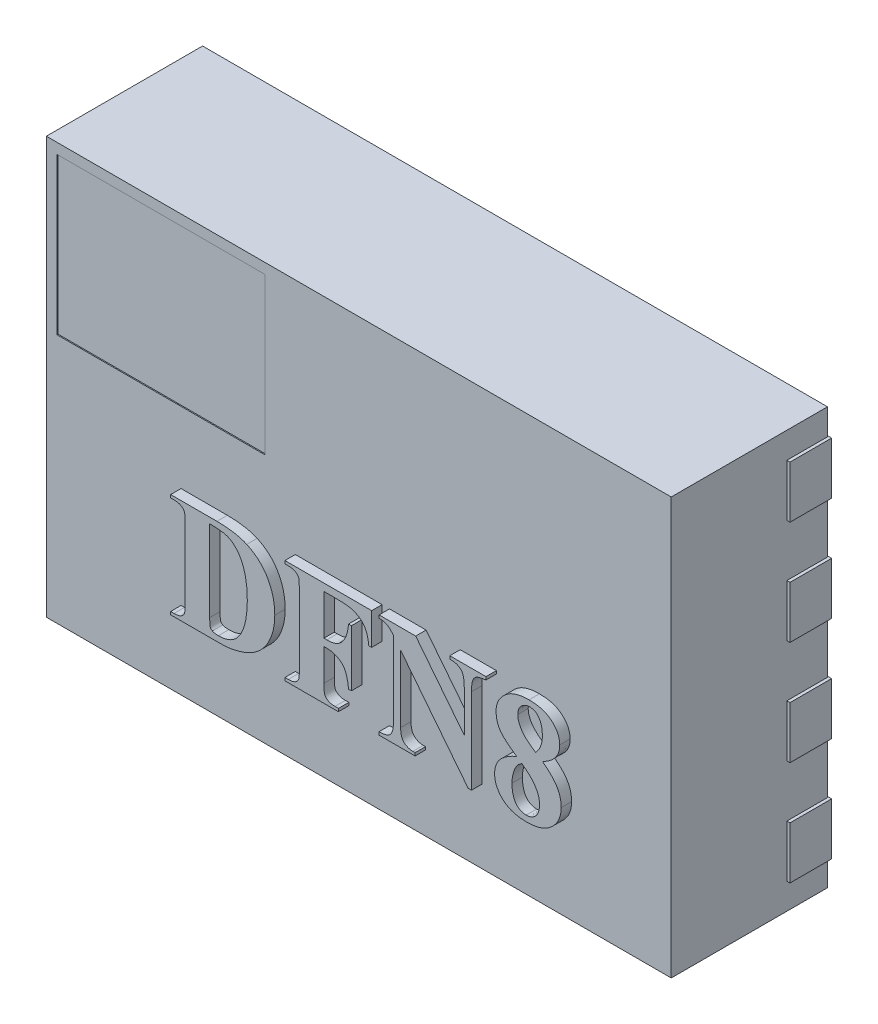
from build123d import *

# Parameters (mm, degrees)
SKETCH1_W         = 0.35
SKETCH1_H         = 0.25
PIN1_DEPTH        = 0.2
LPATTERN1_COUNT   = 4
LPATTERN1_PITCH   = 0.5
LPATTERN1_2_COUNT = 2
LPATTERN1_2_PITCH = 2.67
GND_PAD_DEPTH     = 0.2
BODY_START        = 0.005
SKETCH2_W         = 3
SKETCH2_H         = 2
BODY_DEPTH        = 0.75
SKETCH3_W         = 1
SKETCH3_H         = 0.75
PIN1SILK_DEPTH    = 0.005
TEXT_2_DEPTH      = 0.05


with BuildPart() as part:
    # Sketch1 → Pin1 (new body)
    with BuildSketch(Plane.XY):
        with Locations((-1.33, 0.75)):
            Rectangle(SKETCH1_W, SKETCH1_H)
    extrude(amount=PIN1_DEPTH)


with BuildPart() as lpattern1_1:
    # LPattern1: pattern copy
    add(part.part.moved(Location(Vector(0, -1, 0) * (1 * LPATTERN1_PITCH))))


with BuildPart() as lpattern1_2:
    # LPattern1: pattern copy
    add(part.part.moved(Location(Vector(0, -1, 0) * (2 * LPATTERN1_PITCH))))


with BuildPart() as lpattern1_3:
    # LPattern1: pattern copy
    add(part.part.moved(Location(Vector(0, -1, 0) * (3 * LPATTERN1_PITCH))))


with BuildPart() as lpattern1_2_1:
    # LPattern1 2: pattern copy
    add(part.part.moved(Location(Vector(1, 0, 0) * (1 * LPATTERN1_2_PITCH))))


with BuildPart() as lpattern1_2_2:
    # LPattern1 2: pattern copy
    add(lpattern1_1.part.moved(Location(Vector(1, 0, 0) * (1 * LPATTERN1_2_PITCH))))


with BuildPart() as lpattern1_2_3:
    # LPattern1 2: pattern copy
    add(lpattern1_2.part.moved(Location(Vector(1, 0, 0) * (1 * LPATTERN1_2_PITCH))))


with BuildPart() as lpattern1_2_4:
    # LPattern1 2: pattern copy
    add(lpattern1_3.part.moved(Location(Vector(1, 0, 0) * (1 * LPATTERN1_2_PITCH))))


with BuildPart() as body_9:
    # Sketch5 → GND Pad (new body)
    with BuildSketch(Plane.XY):
        Polygon((-0.8, 0.625), (-0.8, -0.875), (0.8, -0.875), (0.8, 0.875), (-0.55, 0.875), align=None)
    extrude(amount=GND_PAD_DEPTH)


with BuildPart() as body_10:
    # Sketch2 → Body (new body)
    with BuildSketch(Plane.XY.offset(BODY_START)):
        Rectangle(SKETCH2_W, SKETCH2_H)
    extrude(amount=BODY_DEPTH)

    # Sketch3 → Pin1Silk (cut)
    with BuildSketch(Plane.XY.offset(0.755)):
        with Locations((-0.95, 0.575)):
            Rectangle(SKETCH3_W, SKETCH3_H)
    extrude(amount=-PIN1SILK_DEPTH, mode=Mode.SUBTRACT)

    # Sketch4 → Text 2 (add)
    with BuildSketch(Plane.XY.offset(0.755)):
        with BuildLine():
            Line((-0.853439039, -0.641718596), (-0.853439039, -0.627829707))
            Line((-0.853439039, -0.627829707), (-0.83705449, -0.627829707))
            add(Edge.make_bspline(
                [(-0.83705449, -0.627829707), (-0.833687334, -0.627746651), (-0.82736331, -0.627590659), (-0.818467102, -0.626447332), (-0.810794009, -0.62441271), (-0.804232633, -0.621569447), (-0.798702489, -0.617944371), (-0.794132034, -0.61359543), (-0.790073281, -0.608852383), (-0.788193462, -0.605160463), (-0.787249803, -0.603307137)],
                knots=[0, 0, 0, 0, 1.01e-05, 1.897e-05, 2.6841e-05, 3.3836e-05, 4.0337e-05, 4.6556e-05, 5.2725e-05, 5.8943e-05, 5.8943e-05, 5.8943e-05, 5.8943e-05], degree=3))
            add(Edge.make_bspline(
                [(-0.787249803, -0.603307137), (-0.786979018, -0.602516248), (-0.786349397, -0.600677289), (-0.78575319, -0.597355696), (-0.785265317, -0.593148272), (-0.784657565, -0.588021131), (-0.784400039, -0.581932941), (-0.784214458, -0.574914851), (-0.783928713, -0.56695912), (-0.783971802, -0.561351402), (-0.783994594, -0.558385262)],
                knots=[0, 0, 0, 0, 2.505e-06, 5.825e-06, 1.0091e-05, 1.522e-05, 2.1305e-05, 2.8361e-05, 3.6285e-05, 4.5183e-05, 4.5183e-05, 4.5183e-05, 4.5183e-05], degree=3))
            Line((-0.783994594, -0.558385262), (-0.783994594, -0.225051929))
            add(Edge.make_bspline(
                [(-0.783994594, -0.225051929), (-0.784036115, -0.222122368), (-0.784115569, -0.216516379), (-0.784144902, -0.208555203), (-0.784497478, -0.20146459), (-0.784931302, -0.195280025), (-0.785404842, -0.189906227), (-0.786220517, -0.185439581), (-0.786868342, -0.181764352), (-0.788233781, -0.178084137), (-0.790408435, -0.17406242), (-0.794093677, -0.169823469), (-0.798720342, -0.165907534), (-0.804297503, -0.162296624), (-0.8109494, -0.159228014), (-0.818720998, -0.157133088), (-0.827533138, -0.155811615), (-0.833757735, -0.155678164), (-0.83705449, -0.155607484)],
                knots=[0, 0, 0, 0, 8.79e-06, 1.682e-05, 2.388e-05, 3.0081e-05, 3.5425e-05, 4.0045e-05, 4.3706e-05, 4.6589e-05, 5.1785e-05, 5.7328e-05, 6.333e-05, 6.9922e-05, 7.7204e-05, 8.5208e-05, 9.3986e-05, 0.00010387, 0.00010387, 0.00010387, 0.00010387], degree=3))
            Line((-0.83705449, -0.155607484), (-0.853439039, -0.155607484))
            Line((-0.853439039, -0.155607484), (-0.853439039, -0.141718596))
            Line((-0.853439039, -0.141718596), (-0.631216816, -0.141718596))
            add(Edge.make_bspline(
                [(-0.631216816, -0.141718596), (-0.623980719, -0.141755789), (-0.609859593, -0.141828371), (-0.589272147, -0.14312444), (-0.56973912, -0.144851258), (-0.551330125, -0.147641915), (-0.533902002, -0.150881501), (-0.517641087, -0.155206189), (-0.502333207, -0.159935585), (-0.492767902, -0.164026249), (-0.488096157, -0.166024151)],
                knots=[0, 0, 0, 0, 2.1704e-05, 4.2355e-05, 6.1865e-05, 8.0509e-05, 9.8193e-05, 0.000115011, 0.000130967, 0.0001462, 0.0001462, 0.0001462, 0.0001462], degree=3))
            add(Edge.make_bspline(
                [(-0.488096157, -0.166024151), (-0.482695569, -0.168573444), (-0.4719968, -0.173623689), (-0.456962339, -0.182702174), (-0.442901075, -0.192610428), (-0.429759756, -0.203371809), (-0.41775139, -0.215246492), (-0.40661543, -0.227984215), (-0.396481668, -0.241675539), (-0.387532569, -0.256369761), (-0.379522532, -0.271707011), (-0.372608714, -0.287614434), (-0.366509561, -0.303936049), (-0.361863946, -0.320890558), (-0.357959372, -0.338250532), (-0.355456427, -0.35614468), (-0.35372988, -0.374504419), (-0.353536811, -0.386940117), (-0.353439039, -0.393237693)],
                knots=[0, 0, 0, 0, 1.7906e-05, 3.5473e-05, 5.2603e-05, 6.9483e-05, 8.6363e-05, 0.000103206, 0.000120198, 0.000137394, 0.000154768, 0.000172066, 0.000189401, 0.000206989, 0.00022476, 0.000242745, 0.000261155, 0.000280043, 0.000280043, 0.000280043, 0.000280043], degree=3))
            add(Edge.make_bspline(
                [(-0.353439039, -0.393237693), (-0.353647749, -0.401856044), (-0.354058703, -0.418825701), (-0.357295905, -0.443732585), (-0.362436399, -0.467663243), (-0.369864617, -0.490302539), (-0.378745634, -0.511495611), (-0.389176663, -0.530823487), (-0.400563632, -0.548409837), (-0.413510763, -0.563909326), (-0.427569095, -0.577622689), (-0.442408807, -0.590122366), (-0.458498909, -0.600929113), (-0.475583695, -0.610673823), (-0.494313784, -0.618913438), (-0.514758766, -0.626188324), (-0.537198947, -0.632329298), (-0.552891199, -0.635584869), (-0.561012823, -0.637269811)],
                knots=[0, 0, 0, 0, 2.5847e-05, 5.0894e-05, 7.5221e-05, 9.9172e-05, 0.000122268, 0.000144065, 0.000164981, 0.000185015, 0.000204504, 0.000223843, 0.000243134, 0.000262569, 0.000282774, 0.00030443, 0.000327623, 0.000352503, 0.000352503, 0.000352503, 0.000352503], degree=3))
            add(Edge.make_bspline(
                [(-0.561012823, -0.637269811), (-0.565237417, -0.637975595), (-0.574728588, -0.639561243), (-0.590722491, -0.640821986), (-0.609906529, -0.641506451), (-0.623765156, -0.641644414), (-0.631216816, -0.641718596)],
                knots=[0, 0, 0, 0, 1.2845e-05, 2.8857e-05, 4.8078e-05, 7.0433e-05, 7.0433e-05, 7.0433e-05, 7.0433e-05], degree=3))
            Line((-0.631216816, -0.641718596), (-0.853439039, -0.641718596))
        make_face()
        with BuildLine():
            Line((-0.665939039, -0.169496373), (-0.665939039, -0.559687346))
            add(Edge.make_bspline(
                [(-0.665939039, -0.559687346), (-0.665900774, -0.564353951), (-0.66583222, -0.572714416), (-0.665307851, -0.583756857), (-0.66461661, -0.591835642), (-0.663108203, -0.598556142), (-0.659262453, -0.604279592), (-0.655126362, -0.607017227), (-0.653026712, -0.608406964)],
                knots=[0, 0, 0, 0, 1.3999e-05, 2.508e-05, 3.3156e-05, 3.8315e-05, 4.5598e-05, 5.3107e-05, 5.3107e-05, 5.3107e-05, 5.3107e-05], degree=3))
            add(Edge.make_bspline(
                [(-0.653026712, -0.608406964), (-0.651204647, -0.609264958), (-0.647282053, -0.611112071), (-0.640505741, -0.612681664), (-0.632703499, -0.613830729), (-0.627135397, -0.61390251), (-0.624163865, -0.613940818)],
                knots=[0, 0, 0, 0, 6.027e-06, 1.2975e-05, 2.0755e-05, 2.9658e-05, 2.9658e-05, 2.9658e-05, 2.9658e-05], degree=3))
            add(Edge.make_bspline(
                [(-0.624163865, -0.613940818), (-0.619166766, -0.613819212), (-0.609421831, -0.613582065), (-0.595219835, -0.61163695), (-0.581970127, -0.60823412), (-0.569552939, -0.603746471), (-0.558217269, -0.597659284), (-0.547667921, -0.590468009), (-0.538033991, -0.581881183), (-0.532537139, -0.575208096), (-0.529762823, -0.571840123)],
                knots=[0, 0, 0, 0, 1.4988e-05, 2.9229e-05, 4.2887e-05, 5.5968e-05, 6.8734e-05, 8.1374e-05, 9.4206e-05, 0.000107282, 0.000107282, 0.000107282, 0.000107282], degree=3))
            add(Edge.make_bspline(
                [(-0.529762823, -0.571840123), (-0.526162261, -0.566857851), (-0.518776153, -0.556637335), (-0.509874043, -0.539271315), (-0.502307173, -0.520060933), (-0.495989879, -0.498947973), (-0.4913285, -0.475834003), (-0.487911448, -0.450827911), (-0.485664139, -0.423877418), (-0.485479103, -0.405250542), (-0.485383483, -0.395624846)],
                knots=[0, 0, 0, 0, 1.8419e-05, 3.7785e-05, 5.8337e-05, 8.0308e-05, 0.000103802, 0.000128999, 0.000155996, 0.000184866, 0.000184866, 0.000184866, 0.000184866], degree=3))
            add(Edge.make_bspline(
                [(-0.485383483, -0.395624846), (-0.485454142, -0.387810053), (-0.485591985, -0.372564818), (-0.48703023, -0.350295271), (-0.489367016, -0.329209999), (-0.492756155, -0.309334446), (-0.496899873, -0.290639691), (-0.502169841, -0.273182871), (-0.508212543, -0.256858546), (-0.513288253, -0.246713322), (-0.515765428, -0.241761998)],
                knots=[0, 0, 0, 0, 2.3442e-05, 4.573e-05, 6.6915e-05, 8.7055e-05, 0.000106192, 0.000124318, 0.000141729, 0.000158327, 0.000158327, 0.000158327, 0.000158327], degree=3))
            add(Edge.make_bspline(
                [(-0.515765428, -0.241761998), (-0.517786645, -0.238158306), (-0.521760945, -0.231072403), (-0.528286097, -0.221057086), (-0.535589162, -0.212178345), (-0.542985441, -0.203948157), (-0.551028046, -0.196787203), (-0.559299531, -0.190308841), (-0.568212606, -0.184970462), (-0.574406568, -0.182033611), (-0.577505879, -0.180564082)],
                knots=[0, 0, 0, 0, 1.2395e-05, 2.4373e-05, 3.5795e-05, 4.6853e-05, 5.7531e-05, 6.8057e-05, 7.8329e-05, 8.8617e-05, 8.8617e-05, 8.8617e-05, 8.8617e-05], degree=3))
            add(Edge.make_bspline(
                [(-0.577505879, -0.180564082), (-0.57991359, -0.179613444), (-0.584975995, -0.177614652), (-0.593358964, -0.175414113), (-0.60276838, -0.173447894), (-0.613324252, -0.171993564), (-0.624941774, -0.170811691), (-0.63764261, -0.169931888), (-0.651432616, -0.169537707), (-0.660983715, -0.169510493), (-0.665939039, -0.169496373)],
                knots=[0, 0, 0, 0, 7.76e-06, 1.6315e-05, 2.5955e-05, 3.6589e-05, 4.8261e-05, 6.0986e-05, 7.4773e-05, 8.9639e-05, 8.9639e-05, 8.9639e-05, 8.9639e-05], degree=3))
        make_face(mode=Mode.SUBTRACT)
        with BuildLine():
            Line((-0.117327928, -0.176440818), (-0.117327928, -0.370885262))
            Line((-0.117327928, -0.370885262), (-0.103439039, -0.370885262))
            add(Edge.make_bspline(
                [(-0.103439039, -0.370885262), (-0.098367819, -0.370781656), (-0.088685137, -0.370583835), (-0.074871201, -0.368514438), (-0.062534123, -0.365080776), (-0.051456257, -0.360258851), (-0.041532204, -0.353631442), (-0.032525136, -0.34524101), (-0.024435323, -0.334885233), (-0.017010343, -0.322779935), (-0.010590147, -0.308511686), (-0.005427257, -0.291979416), (-0.001590931, -0.273173703), (-6.9679e-05, -0.259825605), (0.000727628, -0.252829707)],
                knots=[0, 0, 0, 0, 1.5205e-05, 2.9031e-05, 4.1775e-05, 5.353e-05, 6.5117e-05, 7.7401e-05, 9.0297e-05, 0.000104422, 0.000119913, 0.000137105, 0.000156279, 0.000177396, 0.000177396, 0.000177396, 0.000177396], degree=3))
            Line((0.000727628, -0.252829707), (0.014616517, -0.252829707))
            Line((0.014616517, -0.252829707), (0.014616517, -0.52366304))
            Line((0.014616517, -0.52366304), (0.000727628, -0.52366304))
            add(Edge.make_bspline(
                [(0.000727628, -0.52366304), (0.000100186, -0.517904511), (-0.001103792, -0.506854657), (-0.003786122, -0.491077111), (-0.00722716, -0.476815156), (-0.011387808, -0.464070939), (-0.016404164, -0.452920748), (-0.022018177, -0.443238719), (-0.028434223, -0.435096202), (-0.037905245, -0.426480697), (-0.050875734, -0.418183137), (-0.067497056, -0.410886979), (-0.085153296, -0.406367653), (-0.097300274, -0.405862683), (-0.103439039, -0.405607484)],
                knots=[0, 0, 0, 0, 1.7375e-05, 3.3341e-05, 4.7973e-05, 6.1355e-05, 7.3497e-05, 8.4588e-05, 9.4857e-05, 0.000104455, 0.000122874, 0.000140755, 0.000158756, 0.000177148, 0.000177148, 0.000177148, 0.000177148], degree=3))
            Line((-0.103439039, -0.405607484), (-0.117327928, -0.405607484))
            Line((-0.117327928, -0.405607484), (-0.117327928, -0.558385262))
            add(Edge.make_bspline(
                [(-0.117327928, -0.558385262), (-0.117287766, -0.561314912), (-0.117210914, -0.566921074), (-0.117164068, -0.574881093), (-0.116866822, -0.581978212), (-0.116259006, -0.588190194), (-0.115775522, -0.593554077), (-0.11515024, -0.598094341), (-0.114326836, -0.60173103), (-0.113022118, -0.605465412), (-0.110630195, -0.609353962), (-0.107029227, -0.613623095), (-0.102379839, -0.617526788), (-0.096809656, -0.621141457), (-0.0901556, -0.624208903), (-0.082384658, -0.626304184), (-0.073608181, -0.627620193), (-0.06741999, -0.627757409), (-0.064159525, -0.627829707)],
                knots=[0, 0, 0, 0, 8.79e-06, 1.682e-05, 2.388e-05, 3.0089e-05, 3.5541e-05, 4.0038e-05, 4.3828e-05, 4.6711e-05, 5.1866e-05, 5.7409e-05, 6.3411e-05, 7.0003e-05, 7.7286e-05, 8.5289e-05, 9.4067e-05, 0.000103842, 0.000103842, 0.000103842, 0.000103842], degree=3))
            Line((-0.064159525, -0.627829707), (-0.047883483, -0.627829707))
            Line((-0.047883483, -0.627829707), (-0.047883483, -0.641718596))
            Line((-0.047883483, -0.641718596), (-0.304827928, -0.641718596))
            Line((-0.304827928, -0.641718596), (-0.304827928, -0.627829707))
            Line((-0.304827928, -0.627829707), (-0.288443379, -0.627829707))
            add(Edge.make_bspline(
                [(-0.288443379, -0.627829707), (-0.285037142, -0.627766079), (-0.278553583, -0.627644969), (-0.269339512, -0.626205587), (-0.26111476, -0.623926045), (-0.256259349, -0.621501707), (-0.253938171, -0.620342727)],
                knots=[0, 0, 0, 0, 1.0209e-05, 1.9432e-05, 2.7913e-05, 3.5681e-05, 3.5681e-05, 3.5681e-05, 3.5681e-05], degree=3))
            add(Edge.make_bspline(
                [(-0.253938171, -0.620342727), (-0.252413244, -0.619422814), (-0.24932867, -0.617562042), (-0.245367118, -0.613620421), (-0.242010007, -0.608815634), (-0.240286525, -0.605180626), (-0.23939824, -0.603307137)],
                knots=[0, 0, 0, 0, 5.327e-06, 1.0775e-05, 1.6615e-05, 2.2827e-05, 2.2827e-05, 2.2827e-05, 2.2827e-05], degree=3))
            add(Edge.make_bspline(
                [(-0.23939824, -0.603307137), (-0.239043829, -0.602447674), (-0.238236494, -0.600489851), (-0.237636241, -0.5969789), (-0.236765862, -0.592705214), (-0.236326645, -0.587504829), (-0.235883568, -0.581430652), (-0.235538197, -0.574520136), (-0.235501977, -0.56674004), (-0.23542452, -0.561278673), (-0.235383483, -0.558385262)],
                knots=[0, 0, 0, 0, 2.781e-06, 6.336e-06, 1.0635e-05, 1.5871e-05, 2.1963e-05, 2.8915e-05, 3.662e-05, 4.5301e-05, 4.5301e-05, 4.5301e-05, 4.5301e-05], degree=3))
            Line((-0.235383483, -0.558385262), (-0.235383483, -0.225051929))
            add(Edge.make_bspline(
                [(-0.235383483, -0.225051929), (-0.235425004, -0.222122368), (-0.235504458, -0.216516379), (-0.235533791, -0.208555203), (-0.235886366, -0.20146459), (-0.236320191, -0.195280025), (-0.236793731, -0.189906227), (-0.237609406, -0.185439581), (-0.23825723, -0.181764352), (-0.23962267, -0.178084137), (-0.241797324, -0.17406242), (-0.245482566, -0.169823469), (-0.250109231, -0.165907534), (-0.255686391, -0.162296624), (-0.262338289, -0.159228014), (-0.270109887, -0.157133088), (-0.278922027, -0.155811615), (-0.285146624, -0.155678164), (-0.288443379, -0.155607484)],
                knots=[0, 0, 0, 0, 8.79e-06, 1.682e-05, 2.388e-05, 3.0081e-05, 3.5425e-05, 4.0045e-05, 4.3706e-05, 4.6589e-05, 5.1785e-05, 5.7328e-05, 6.333e-05, 6.9922e-05, 7.7204e-05, 8.5208e-05, 9.3986e-05, 0.00010387, 0.00010387, 0.00010387, 0.00010387], degree=3))
            Line((-0.288443379, -0.155607484), (-0.304827928, -0.155607484))
            Line((-0.304827928, -0.155607484), (-0.304827928, -0.141718596))
            Line((-0.304827928, -0.141718596), (0.111838739, -0.141718596))
            Line((0.111838739, -0.141718596), (0.111838739, -0.294496373))
            Line((0.111838739, -0.294496373), (0.09794985, -0.294496373))
            add(Edge.make_bspline(
                [(0.09794985, -0.294496373), (0.097492972, -0.290294012), (0.096607303, -0.282147644), (0.094509758, -0.270421464), (0.092017396, -0.259519581), (0.089141303, -0.249414332), (0.085681738, -0.240148152), (0.081654822, -0.231777779), (0.07719699, -0.224191934), (0.070527487, -0.215208895), (0.060562558, -0.205356176), (0.04643117, -0.195494884), (0.029974784, -0.187502359), (0.017934618, -0.183934556), (0.011686829, -0.182083179)],
                knots=[0, 0, 0, 0, 1.2678e-05, 2.4577e-05, 3.5711e-05, 4.6219e-05, 5.6074e-05, 6.5343e-05, 7.4052e-05, 8.2429e-05, 9.8848e-05, 0.000115827, 0.000133928, 0.000153452, 0.000153452, 0.000153452, 0.000153452], degree=3))
            add(Edge.make_bspline(
                [(0.011686829, -0.182083179), (0.009701467, -0.181629801), (0.005356322, -0.180637542), (-0.001814984, -0.179473945), (-0.010143588, -0.178519799), (-0.019629811, -0.177804537), (-0.030261891, -0.177126947), (-0.042057337, -0.176715635), (-0.055008132, -0.176526253), (-0.064014794, -0.176470122), (-0.068716816, -0.176440818)],
                knots=[0, 0, 0, 0, 6.108e-06, 1.3369e-05, 2.178e-05, 3.1251e-05, 4.1905e-05, 5.374e-05, 6.6654e-05, 8.076e-05, 8.076e-05, 8.076e-05, 8.076e-05], degree=3))
            Line((-0.068716816, -0.176440818), (-0.117327928, -0.176440818))
        make_face()
        with BuildLine():
            Line((0.323210267, -0.141718596), (0.556283184, -0.437617033))
            Line((0.556283184, -0.437617033), (0.556283184, -0.238940818))
            add(Edge.make_bspline(
                [(0.556283184, -0.238940818), (0.556233091, -0.235251308), (0.556137268, -0.228193622), (0.555650051, -0.218085021), (0.554626176, -0.208933859), (0.553439554, -0.200634862), (0.551549056, -0.193339142), (0.549527847, -0.18691546), (0.547084152, -0.181396634), (0.544935469, -0.178258889), (0.543913392, -0.176766339)],
                knots=[0, 0, 0, 0, 1.107e-05, 2.1176e-05, 3.0342e-05, 3.8691e-05, 4.6297e-05, 5.2919e-05, 5.8891e-05, 6.4309e-05, 6.4309e-05, 6.4309e-05, 6.4309e-05], degree=3))
            add(Edge.make_bspline(
                [(0.543913392, -0.176766339), (0.542402713, -0.175023055), (0.539376895, -0.171531341), (0.533985285, -0.167036252), (0.527860573, -0.163347425), (0.521022611, -0.160405715), (0.513483647, -0.158146244), (0.505238274, -0.15652272), (0.496260806, -0.15567845), (0.49005942, -0.155631742), (0.486838739, -0.155607484)],
                knots=[0, 0, 0, 0, 6.912e-06, 1.3845e-05, 2.0953e-05, 2.8291e-05, 3.6117e-05, 4.4523e-05, 5.3463e-05, 6.3122e-05, 6.3122e-05, 6.3122e-05, 6.3122e-05], degree=3))
            Line((0.486838739, -0.155607484), (0.486838739, -0.141718596))
            Line((0.486838739, -0.141718596), (0.66044985, -0.141718596))
            Line((0.66044985, -0.141718596), (0.66044985, -0.155607484))
            add(Edge.make_bspline(
                [(0.66044985, -0.155607484), (0.655301684, -0.156255436), (0.645900879, -0.157438626), (0.633268164, -0.160076695), (0.623295791, -0.162745179), (0.615643865, -0.165922648), (0.60979578, -0.170027673), (0.605008971, -0.175030252), (0.600728042, -0.180956516), (0.596993035, -0.188174747), (0.594157915, -0.197326868), (0.592377324, -0.208861051), (0.591219858, -0.223002949), (0.591080879, -0.23333171), (0.591005406, -0.238940818)],
                knots=[0, 0, 0, 0, 1.556e-05, 2.8413e-05, 3.8683e-05, 4.6505e-05, 5.3127e-05, 5.9957e-05, 6.7184e-05, 7.4997e-05, 8.4228e-05, 9.5788e-05, 0.000109944, 0.000126768, 0.000126768, 0.000126768, 0.000126768], degree=3))
            Line((0.591005406, -0.238940818), (0.591005406, -0.64866304))
            Line((0.591005406, -0.64866304), (0.575054885, -0.64866304))
            Line((0.575054885, -0.64866304), (0.250727628, -0.236662172))
            Line((0.250727628, -0.236662172), (0.250727628, -0.558385262))
            add(Edge.make_bspline(
                [(0.250727628, -0.558385262), (0.25080733, -0.561641289), (0.250960754, -0.567909084), (0.25164238, -0.576916068), (0.253059769, -0.585080875), (0.255000473, -0.59242665), (0.257471264, -0.598955871), (0.260482384, -0.604715867), (0.264240603, -0.609511993), (0.269756195, -0.614888679), (0.277608339, -0.619976057), (0.28765896, -0.62455556), (0.298391491, -0.627369715), (0.305796539, -0.627675294), (0.309538392, -0.627829707)],
                knots=[0, 0, 0, 0, 9.771e-06, 1.8809e-05, 2.7068e-05, 3.4596e-05, 4.1569e-05, 4.7977e-05, 5.4011e-05, 5.9765e-05, 7.1021e-05, 8.1851e-05, 9.2825e-05, 0.000104035, 0.000104035, 0.000104035, 0.000104035], degree=3))
            Line((0.309538392, -0.627829707), (0.320172072, -0.627829707))
            Line((0.320172072, -0.627829707), (0.320172072, -0.641718596))
            Line((0.320172072, -0.641718596), (0.146560961, -0.641718596))
            Line((0.146560961, -0.641718596), (0.146560961, -0.627829707))
            add(Edge.make_bspline(
                [(0.146560961, -0.627829707), (0.149673098, -0.627754685), (0.155653514, -0.62761052), (0.164283731, -0.626864946), (0.172207561, -0.625615463), (0.179361275, -0.623718487), (0.185844072, -0.621622759), (0.191553602, -0.61891021), (0.196473202, -0.615600245), (0.200799116, -0.611896728), (0.204461964, -0.607517961), (0.207604981, -0.602520225), (0.210204259, -0.596774443), (0.212354289, -0.590415465), (0.213969527, -0.583357943), (0.215125476, -0.575668101), (0.215926938, -0.567263328), (0.215978535, -0.561425502), (0.216005406, -0.558385262)],
                knots=[0, 0, 0, 0, 9.337e-06, 1.7943e-05, 2.597e-05, 3.3365e-05, 4.0125e-05, 4.6386e-05, 5.2254e-05, 5.7868e-05, 6.3412e-05, 6.9312e-05, 7.5526e-05, 8.2286e-05, 8.9419e-05, 9.7215e-05, 0.000105604, 0.000114721, 0.000114721, 0.000114721, 0.000114721], degree=3))
            Line((0.216005406, -0.558385262), (0.216005406, -0.192716859))
            Line((0.216005406, -0.192716859), (0.210037524, -0.18522988))
            add(Edge.make_bspline(
                [(0.210037524, -0.18522988), (0.207550958, -0.182473809), (0.202868249, -0.177283569), (0.195640383, -0.170665575), (0.18884416, -0.165574924), (0.182269668, -0.161695106), (0.175140095, -0.159198865), (0.167094663, -0.157174009), (0.157688211, -0.156125768), (0.150975045, -0.155786626), (0.147429017, -0.155607484)],
                knots=[0, 0, 0, 0, 1.1132e-05, 2.0964e-05, 2.934e-05, 3.6581e-05, 4.3757e-05, 5.1915e-05, 6.143e-05, 7.2084e-05, 7.2084e-05, 7.2084e-05, 7.2084e-05], degree=3))
            Line((0.147429017, -0.155607484), (0.147429017, -0.141718596))
            Line((0.147429017, -0.141718596), (0.323210267, -0.141718596))
        make_face()
        with BuildLine():
            add(Edge.make_bspline(
                [(0.932368253, -0.358623977), (0.936401323, -0.361783799), (0.944233016, -0.367919757), (0.955349883, -0.37724641), (0.965417543, -0.386510872), (0.974666592, -0.395431964), (0.98285825, -0.404297508), (0.990144616, -0.412981502), (0.996570261, -0.421476139), (1.003672895, -0.432682433), (1.010911483, -0.447130808), (1.017181196, -0.465618513), (1.020926663, -0.485353098), (1.021346861, -0.498943361), (1.021560961, -0.505867901)],
                knots=[0, 0, 0, 0, 1.537e-05, 2.9847e-05, 4.3518e-05, 5.6409e-05, 6.8387e-05, 7.9709e-05, 9.0408e-05, 0.000100312, 0.000119479, 0.000138729, 0.000158712, 0.000179472, 0.000179472, 0.000179472, 0.000179472], degree=3))
            add(Edge.make_bspline(
                [(1.021560961, -0.505867901), (1.021460673, -0.510760249), (1.021262771, -0.520414472), (1.018945697, -0.534574828), (1.015557723, -0.548206863), (1.010567476, -0.561240494), (1.004336542, -0.573737405), (0.996462681, -0.585550682), (0.987368046, -0.596869316), (0.976822404, -0.607437324), (0.965231984, -0.617220011), (0.952360775, -0.625601726), (0.938611301, -0.632791046), (0.923774908, -0.638535334), (0.907989689, -0.643122416), (0.891166821, -0.646306541), (0.873353244, -0.648319932), (0.861157182, -0.648546628), (0.854894295, -0.64866304)],
                knots=[0, 0, 0, 0, 1.4663e-05, 2.8935e-05, 4.2936e-05, 5.674e-05, 7.0716e-05, 8.474e-05, 9.9246e-05, 0.000114208, 0.000129462, 0.00014466, 0.00016019, 0.000175927, 0.000192307, 0.000209438, 0.000227232, 0.000246015, 0.000246015, 0.000246015, 0.000246015], degree=3))
            add(Edge.make_bspline(
                [(0.854894295, -0.64866304), (0.84899413, -0.648574094), (0.837492205, -0.648400702), (0.820773008, -0.646617521), (0.805065276, -0.643813703), (0.790356093, -0.639976832), (0.776721711, -0.634811949), (0.764038757, -0.62868009), (0.752482698, -0.621208888), (0.741946771, -0.612793583), (0.732703754, -0.603429186), (0.724441638, -0.593678061), (0.717621269, -0.583287209), (0.711871916, -0.572502779), (0.707547096, -0.561112525), (0.704378009, -0.549267426), (0.702503405, -0.536887968), (0.702246907, -0.528479837), (0.702116517, -0.524205575)],
                knots=[0, 0, 0, 0, 1.7695e-05, 3.4495e-05, 5.0373e-05, 6.5533e-05, 8.0023e-05, 9.4048e-05, 0.000107713, 0.000121219, 0.000134415, 0.000147127, 0.000159496, 0.00017163, 0.000183721, 0.00019596, 0.000208359, 0.000221179, 0.000221179, 0.000221179, 0.000221179], degree=3))
            add(Edge.make_bspline(
                [(0.702116517, -0.524205575), (0.702154997, -0.520945311), (0.70223095, -0.514510131), (0.703561571, -0.50502448), (0.70527088, -0.495796228), (0.708112161, -0.48695323), (0.711426042, -0.478356897), (0.715556625, -0.470042645), (0.720610423, -0.462166414), (0.726274679, -0.454427552), (0.732991518, -0.44704996), (0.740576123, -0.439763703), (0.74922419, -0.43272508), (0.75880979, -0.425750105), (0.769429467, -0.418947259), (0.781064253, -0.412338677), (0.793710338, -0.405913225), (0.802576771, -0.401917918), (0.807151239, -0.399856616)],
                knots=[0, 0, 0, 0, 9.771e-06, 1.9286e-05, 2.8692e-05, 3.789e-05, 4.7099e-05, 5.6319e-05, 6.5681e-05, 7.5143e-05, 8.5055e-05, 9.5569e-05, 0.00010667, 0.000118477, 0.000131118, 0.000144482, 0.000158604, 0.000173655, 0.000173655, 0.000173655, 0.000173655], degree=3))
            add(Edge.make_bspline(
                [(0.807151239, -0.399856616), (0.801883524, -0.396199733), (0.791796228, -0.389197065), (0.77767643, -0.378629291), (0.765066222, -0.368706581), (0.754031769, -0.359213012), (0.74452133, -0.350292153), (0.736490682, -0.341902905), (0.730018481, -0.33404449), (0.723613458, -0.324097917), (0.71768263, -0.311363), (0.712687526, -0.295224952), (0.709557422, -0.277979495), (0.709229039, -0.266081137), (0.709060961, -0.259991165)],
                knots=[0, 0, 0, 0, 1.9236e-05, 3.6836e-05, 5.2901e-05, 6.7366e-05, 8.0491e-05, 9.2004e-05, 0.000102189, 0.000110977, 0.000127431, 0.000144144, 0.000161556, 0.000179811, 0.000179811, 0.000179811, 0.000179811], degree=3))
            add(Edge.make_bspline(
                [(0.709060961, -0.259991165), (0.709186303, -0.255897249), (0.709434015, -0.24780648), (0.711402977, -0.235873939), (0.714890128, -0.224394441), (0.719373108, -0.213151919), (0.725431352, -0.202382126), (0.732772363, -0.192011523), (0.741410921, -0.182014925), (0.751214966, -0.1723886), (0.762209125, -0.16351152), (0.774333393, -0.155778153), (0.787430295, -0.149246113), (0.801503872, -0.143930854), (0.816545882, -0.139802939), (0.832565857, -0.136953629), (0.849529463, -0.135002211), (0.861181871, -0.134851443), (0.867155579, -0.134774151)],
                knots=[0, 0, 0, 0, 1.2279e-05, 2.4266e-05, 3.6145e-05, 4.8215e-05, 6.0504e-05, 7.3118e-05, 8.6276e-05, 0.000100087, 0.000114288, 0.000128585, 0.000143143, 0.000158116, 0.000173647, 0.000189865, 0.000206892, 0.000224804, 0.000224804, 0.000224804, 0.000224804], degree=3))
            add(Edge.make_bspline(
                [(0.867155579, -0.134774151), (0.872909803, -0.13488149), (0.884077424, -0.135089809), (0.900327665, -0.13660672), (0.915575172, -0.13917524), (0.929797662, -0.142867903), (0.943022431, -0.147491388), (0.955169918, -0.153282768), (0.966285982, -0.160146949), (0.976364801, -0.167965271), (0.98534805, -0.176474059), (0.993059754, -0.18556983), (0.999804204, -0.194929861), (1.005238638, -0.20480214), (1.009363679, -0.215138149), (1.012478211, -0.225803258), (1.014193937, -0.23696879), (1.014474353, -0.244541652), (1.014616517, -0.248380922)],
                knots=[0, 0, 0, 0, 1.7261e-05, 3.35e-05, 4.8912e-05, 6.3598e-05, 7.7532e-05, 9.0878e-05, 0.000103887, 0.000116649, 0.000129082, 0.000140934, 0.000152375, 0.000163641, 0.000174643, 0.000185702, 0.000196905, 0.000208425, 0.000208425, 0.000208425, 0.000208425], degree=3))
            add(Edge.make_bspline(
                [(1.014616517, -0.248380922), (1.014360143, -0.254079438), (1.013858105, -0.265238439), (1.01007641, -0.28147339), (1.003709545, -0.296610247), (0.994727885, -0.310736823), (0.983044045, -0.323873257), (0.968829199, -0.336404623), (0.951708143, -0.348138828), (0.939020456, -0.355017476), (0.932368253, -0.358623977)],
                knots=[0, 0, 0, 0, 1.7085e-05, 3.3457e-05, 4.97e-05, 6.6136e-05, 8.3437e-05, 0.000102271, 0.000122858, 0.00014555, 0.00014555, 0.00014555, 0.00014555], degree=3))
        make_face()
        with BuildLine():
            add(Edge.make_bspline(
                [(0.899273635, -0.337465123), (0.901864127, -0.334510489), (0.907009266, -0.328642106), (0.913621264, -0.319091169), (0.919115432, -0.30896278), (0.923531894, -0.298329602), (0.927047603, -0.287151302), (0.929535981, -0.275455784), (0.930928149, -0.263207558), (0.931163353, -0.254894729), (0.931283184, -0.250659568)],
                knots=[0, 0, 0, 0, 1.1781e-05, 2.34e-05, 3.4761e-05, 4.6288e-05, 5.7888e-05, 6.9869e-05, 8.2104e-05, 9.4811e-05, 9.4811e-05, 9.4811e-05, 9.4811e-05], degree=3))
            add(Edge.make_bspline(
                [(0.931283184, -0.250659568), (0.931212151, -0.246969159), (0.931074754, -0.23983093), (0.930258798, -0.229412216), (0.928610062, -0.219702941), (0.926433761, -0.210641219), (0.923787673, -0.202195859), (0.920277789, -0.194527632), (0.916261963, -0.187433896), (0.913031529, -0.183206899), (0.911426413, -0.181106616)],
                knots=[0, 0, 0, 0, 1.1072e-05, 2.1417e-05, 3.1317e-05, 4.0581e-05, 4.9366e-05, 5.7816e-05, 6.5837e-05, 7.3759e-05, 7.3759e-05, 7.3759e-05, 7.3759e-05], degree=3))
            add(Edge.make_bspline(
                [(0.911426413, -0.181106616), (0.908845634, -0.178240411), (0.903765301, -0.172598209), (0.893765487, -0.166765906), (0.8824807, -0.163190087), (0.87445392, -0.162769478), (0.870302281, -0.162551929)],
                knots=[0, 0, 0, 0, 1.1509e-05, 2.2656e-05, 3.4255e-05, 4.6682e-05, 4.6682e-05, 4.6682e-05, 4.6682e-05], degree=3))
            add(Edge.make_bspline(
                [(0.870302281, -0.162551929), (0.866480893, -0.162753496), (0.858946306, -0.163150923), (0.848124332, -0.166527576), (0.838249806, -0.172107634), (0.829536462, -0.179694703), (0.82229777, -0.188849706), (0.816933836, -0.199254102), (0.813856692, -0.210809655), (0.813441512, -0.218848844), (0.813227628, -0.222990297)],
                knots=[0, 0, 0, 0, 1.1445e-05, 2.2566e-05, 3.3642e-05, 4.5259e-05, 5.7002e-05, 6.8455e-05, 8.0142e-05, 9.2559e-05, 9.2559e-05, 9.2559e-05, 9.2559e-05], degree=3))
            add(Edge.make_bspline(
                [(0.813227628, -0.222990297), (0.813431788, -0.22742469), (0.813847507, -0.236454218), (0.81752689, -0.25002193), (0.823080725, -0.263788889), (0.829413018, -0.275342092), (0.83597969, -0.284561093), (0.841920926, -0.291813042), (0.848974409, -0.299157813), (0.857096636, -0.306528608), (0.866122665, -0.314206626), (0.876277807, -0.32183198), (0.887286994, -0.329831007), (0.895194083, -0.334866916), (0.899273635, -0.337465123)],
                knots=[0, 0, 0, 0, 1.3282e-05, 2.7046e-05, 4.1896e-05, 5.7778e-05, 6.6419e-05, 7.5825e-05, 8.5878e-05, 9.6936e-05, 0.000108718, 0.000121414, 0.000135024, 0.00014953, 0.00014953, 0.00014953, 0.00014953], degree=3))
        make_face(mode=Mode.SUBTRACT)
        with BuildLine():
            add(Edge.make_bspline(
                [(0.832541864, -0.417217727), (0.830172025, -0.418818755), (0.825709415, -0.421833627), (0.8197256, -0.426463396), (0.814856641, -0.430933973), (0.81219042, -0.434013169), (0.810948982, -0.435446894)],
                knots=[0, 0, 0, 0, 8.578e-06, 1.6154e-05, 2.2679e-05, 2.8365e-05, 2.8365e-05, 2.8365e-05, 2.8365e-05], degree=3))
            add(Edge.make_bspline(
                [(0.810948982, -0.435446894), (0.809309116, -0.437730317), (0.805817316, -0.442592456), (0.801288221, -0.451048019), (0.79717217, -0.460991193), (0.79303149, -0.472001629), (0.789763357, -0.483956441), (0.787191089, -0.496336495), (0.785820988, -0.509056336), (0.785574044, -0.517620037), (0.78544985, -0.521926929)],
                knots=[0, 0, 0, 0, 8.427e-06, 1.7944e-05, 2.8687e-05, 4.0702e-05, 5.3207e-05, 6.5826e-05, 7.8599e-05, 9.1523e-05, 9.1523e-05, 9.1523e-05, 9.1523e-05], degree=3))
            add(Edge.make_bspline(
                [(0.78544985, -0.521926929), (0.785549073, -0.52728364), (0.785739975, -0.53758976), (0.787325241, -0.552419526), (0.790156045, -0.565885156), (0.793868218, -0.578011333), (0.798731991, -0.588681614), (0.80473213, -0.597696722), (0.81149744, -0.605360602), (0.819428806, -0.611065039), (0.827771862, -0.615317942), (0.836217693, -0.618593944), (0.84482986, -0.620465612), (0.850618149, -0.620746303), (0.853483704, -0.620885262)],
                knots=[0, 0, 0, 0, 1.6068e-05, 3.0915e-05, 4.4662e-05, 5.7291e-05, 6.8894e-05, 7.9697e-05, 8.9682e-05, 9.9383e-05, 0.000108799, 0.000117726, 0.000126495, 0.000135091, 0.000135091, 0.000135091, 0.000135091], degree=3))
            add(Edge.make_bspline(
                [(0.853483704, -0.620885262), (0.857815587, -0.620675511), (0.866320855, -0.620263684), (0.878472081, -0.616422229), (0.889474071, -0.610155591), (0.899258058, -0.601649942), (0.907501991, -0.591004536), (0.913253173, -0.578175486), (0.916770532, -0.563635753), (0.917180326, -0.553342892), (0.917394295, -0.547968596)],
                knots=[0, 0, 0, 0, 1.2967e-05, 2.546e-05, 3.7802e-05, 5.0725e-05, 6.4115e-05, 7.7855e-05, 9.2593e-05, 0.000108696, 0.000108696, 0.000108696, 0.000108696], degree=3))
            add(Edge.make_bspline(
                [(0.917394295, -0.547968596), (0.917331101, -0.542129054), (0.917204693, -0.530447948), (0.913552237, -0.513020759), (0.907069008, -0.495988804), (0.897663154, -0.479343401), (0.885457178, -0.463145486), (0.870549366, -0.447219117), (0.852772663, -0.431678345), (0.839465698, -0.422166762), (0.832541864, -0.417217727)],
                knots=[0, 0, 0, 0, 1.7486e-05, 3.4978e-05, 5.3076e-05, 7.1972e-05, 9.2133e-05, 0.000113783, 0.000137312, 0.000162833, 0.000162833, 0.000162833, 0.000162833], degree=3))
        make_face(mode=Mode.SUBTRACT)
    extrude(amount=TEXT_2_DEPTH)


solid = Compound([part.part, lpattern1_1.part, lpattern1_2.part, lpattern1_3.part, lpattern1_2_1.part, lpattern1_2_2.part, lpattern1_2_3.part, lpattern1_2_4.part, body_9.part, body_10.part])
